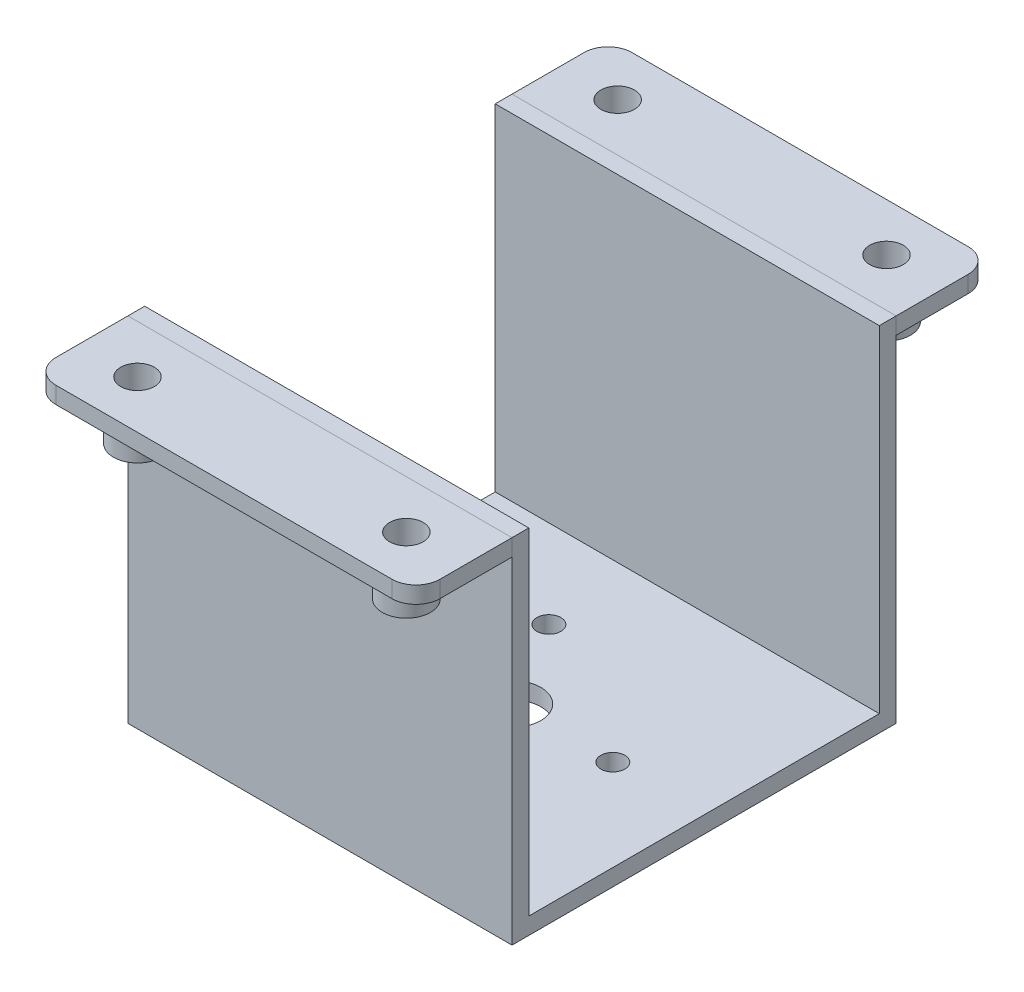
from build123d import *

# Parameters (mm, degrees)
SKETCH1_W             = 80
SKETCH1_H             = 80
SKETCH1_R             = 2.5
SKETCH1_R_2           = 6
BOSS_EXTRUDE1_DEPTH   = 3.5
BOSS_EXTRUDE2_START   = 3.5
SKETCH1_4_W           = 80
SKETCH1_4_H           = 3.5
BOSS_EXTRUDE2_DEPTH   = 70
BOSS_EXTRUDE3_START   = 73.5
SKETCH1_5_W           = 80
SKETCH1_5_H           = 20
SKETCH1_5_R           = 5
BOSS_EXTRUDE3_DEPTH   = 3.5
BOSS_EXTRUDE3_2_DEPTH = 3.5
BOSS_EXTRUDE4_START   = 73.5
SKETCH1_6_R           = 5
SKETCH1_6_R_2         = 3.5
BOSS_EXTRUDE4_DEPTH   = 12
FILLET1_R             = 5
FILLET2_R             = 5


with BuildPart() as part:
    # Sketch1 → Boss-Extrude1 (new body)
    with BuildSketch(Plane(origin=(0, 0, 0), x_dir=(1, 0, 0), z_dir=(0, 1, 0))):
        Rectangle(SKETCH1_W, SKETCH1_H)
        with Locations((21, 0)):
            Circle(SKETCH1_R, mode=Mode.SUBTRACT)
        with Locations((-10.5, -18.186533479)):
            Circle(SKETCH1_R, mode=Mode.SUBTRACT)
        with Locations((-10.5, 18.186533479)):
            Circle(SKETCH1_R, mode=Mode.SUBTRACT)
        Circle(SKETCH1_R_2, mode=Mode.SUBTRACT)
    extrude(amount=BOSS_EXTRUDE1_DEPTH)

    # Sketch1_4 → Boss-Extrude2 (add)
    with BuildSketch(Plane(origin=(0, 0, 0), x_dir=(1, 0, 0), z_dir=(0, 1, 0)).offset(BOSS_EXTRUDE2_START)):
        with Locations((0, 38.25)):
            Rectangle(SKETCH1_4_W, SKETCH1_4_H)
        with Locations((0, -38.25)):
            Rectangle(SKETCH1_4_W, SKETCH1_4_H)
    extrude(amount=BOSS_EXTRUDE2_DEPTH)


with BuildPart() as body_2:
    # Sketch1_5 → Boss-Extrude3 (new body)
    with BuildSketch(Plane(origin=(0, 0, 0), x_dir=(1, 0, 0), z_dir=(0, 1, 0)).offset(BOSS_EXTRUDE3_START)):
        with Locations((0, -50)):
            Rectangle(SKETCH1_5_W, SKETCH1_5_H)
        with Locations((28, -50)):
            Circle(SKETCH1_5_R, mode=Mode.SUBTRACT)
        with Locations((-28, -50)):
            Circle(SKETCH1_5_R, mode=Mode.SUBTRACT)
    extrude(amount=-BOSS_EXTRUDE3_DEPTH)



with BuildPart() as body_3:
    # Sketch1_5 → Boss-Extrude3 2 (new body)
    with BuildSketch(Plane(origin=(0, 0, 0), x_dir=(1, 0, 0), z_dir=(0, 1, 0)).offset(BOSS_EXTRUDE3_START)):
        with Locations((0, 50)):
            Rectangle(SKETCH1_5_W, SKETCH1_5_H)
        with Locations((-28, 50)):
            Circle(SKETCH1_5_R, mode=Mode.SUBTRACT)
        with Locations((28, 50)):
            Circle(SKETCH1_5_R, mode=Mode.SUBTRACT)
    extrude(amount=-BOSS_EXTRUDE3_2_DEPTH)


with BuildPart() as body_2_1:
    add(body_2.part)

    add(body_3.part)  # Boss-Extrude4 merges body 3
    # Sketch1_6 → Boss-Extrude4 (add)
    with BuildSketch(Plane(origin=(0, 0, 0), x_dir=(1, 0, 0), z_dir=(0, 1, 0)).offset(BOSS_EXTRUDE4_START)):
        with Locations((28, -50)):
            Circle(SKETCH1_6_R)
        with Locations((28, -50)):
            Circle(SKETCH1_6_R_2, mode=Mode.SUBTRACT)
        with Locations((-28, -50)):
            Circle(SKETCH1_6_R)
        with Locations((-28, -50)):
            Circle(SKETCH1_6_R_2, mode=Mode.SUBTRACT)
        with Locations((-28, 50)):
            Circle(SKETCH1_6_R)
        with Locations((-28, 50)):
            Circle(SKETCH1_6_R_2, mode=Mode.SUBTRACT)
        with Locations((28, 50)):
            Circle(SKETCH1_6_R)
        with Locations((28, 50)):
            Circle(SKETCH1_6_R_2, mode=Mode.SUBTRACT)
    extrude(amount=-BOSS_EXTRUDE4_DEPTH)

    # Fillet1
    fillet1_edges = [body_2_1.edges().sort_by_distance(p)[0] for p in [
        (40, 71.75, -60),
        (-40, 71.75, -60),
    ]]
    fillet(fillet1_edges, radius=FILLET1_R)

    # Fillet2
    fillet2_edges = [body_2_1.edges().sort_by_distance(p)[0] for p in [
        (-40, 71.75, 60),
        (40, 71.75, 60),
    ]]
    fillet(fillet2_edges, radius=FILLET2_R)


solid = Compound([part.part, body_2_1.part])
